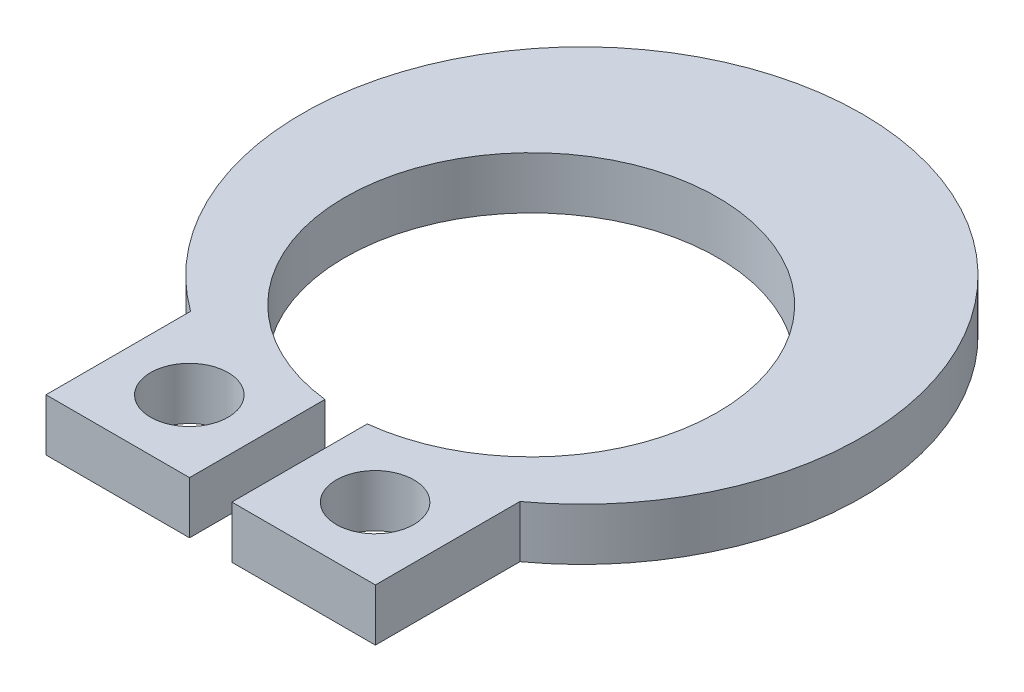
from build123d import *

# Parameters (mm, degrees)
EXTRUDE1_DEPTH     = 0.889
SKETCH5_R          = 0.6604
CUT_EXTRUDE1_DEPTH = 1.889


with BuildPart() as part:
    # Sketch4 → Extrude1 (new body)
    with BuildSketch(Plane(origin=(0, 0, 0), x_dir=(1, 0, 0), z_dir=(0, 1, 0))):
        with BuildLine():
            Line((-2.8067, -5.46211125), (-0.36068, -5.46211125))
            Line((-0.36068, -5.46211125), (-0.36068, -3.154446851))
            ThreePointArc((-0.36068, -3.154446851), (0, 3.175), (0.36068, -3.154446851))
            Line((0.36068, -3.154446851), (0.36068, -5.46211125))
            Line((0.36068, -5.46211125), (2.8067, -5.46211125))
            Line((2.8067, -5.46211125), (2.8067, -2.99831125))
            ThreePointArc((2.8067, -2.99831125), (0, 5.63768875), (-2.8067, -2.99831125))
            Line((-2.8067, -2.99831125), (-2.8067, -5.46211125))
        make_face()
    extrude(amount=EXTRUDE1_DEPTH)

    # Sketch5 → Cut-Extrude1 (cut, through all)
    with BuildSketch(Plane(origin=(0, 0, 0), x_dir=(1, 0, 0), z_dir=(0, 1, 0))):
        with Locations((1.582947052, -4.24322866)):
            Circle(SKETCH5_R)
    cut_extrude1 = extrude(amount=CUT_EXTRUDE1_DEPTH, mode=Mode.SUBTRACT)

    # Mirror1: Cut-Extrude1 across plane
    add(cut_extrude1.mirror(Plane(origin=(0, 0, 0), x_dir=(0, 0, 1), z_dir=(1, 0, 0))), mode=Mode.SUBTRACT)


solid = part.part
